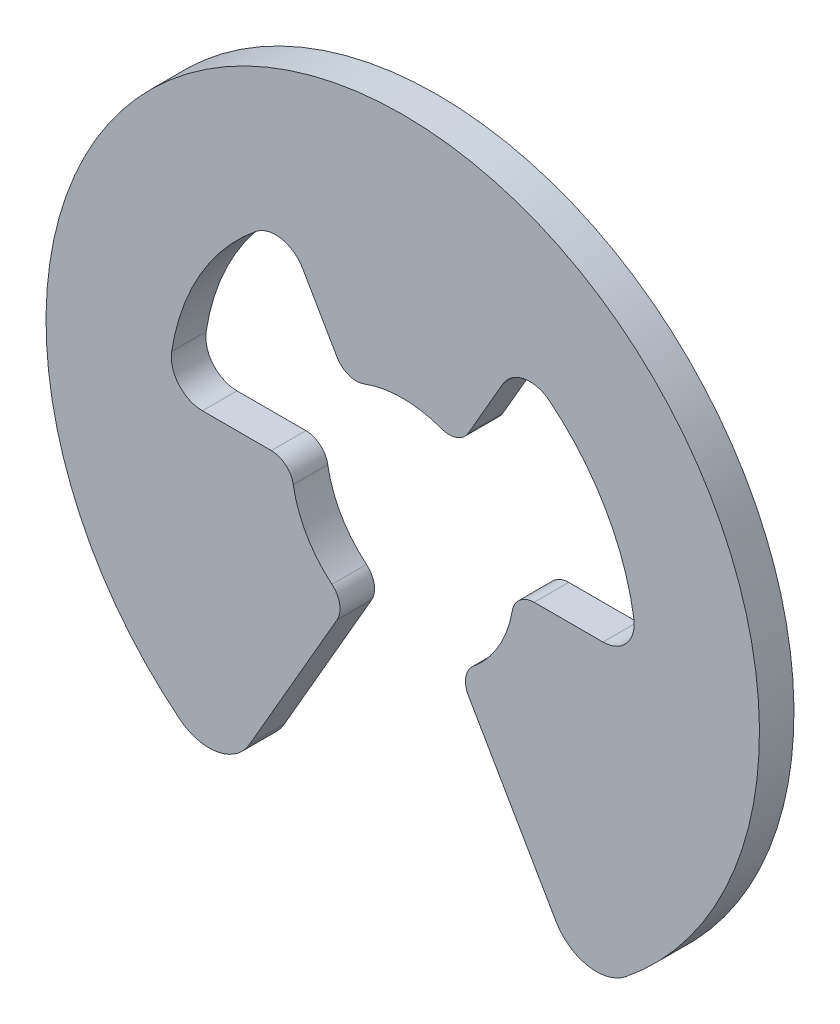
from build123d import *

# Parameters (mm, degrees)
BOSS_EXTRUDE1_DEPTH      = 0.1905
BOSS_EXTRUDE1_DEPTH_BACK = 0.1905


with BuildPart() as part:
    # Sketch1 → Boss-Extrude1 (new, two sides: drawn at the far end of the back side and taken through both)
    with BuildSketch(Plane.XY.offset(-BOSS_EXTRUDE1_DEPTH_BACK)):
        with BuildLine():
            Line((-1.690782151, -2.92852059), (-0.725045158, -1.255815051))
            ThreePointArc((-0.725045158, -1.255815051), (-0.696082706, -1.089842323), (-0.781097204, -0.944383376))
            ThreePointArc((-0.781097204, -0.944383376), (-1.061357434, -0.612775), (-1.208408596, -0.204258333))
            ThreePointArc((-1.208408596, -0.204258333), (-1.291872491, -0.057904145), (-1.450090316, 0))
            Line((-1.450090316, 0), (-2.210471848, 0))
            ThreePointArc((-2.210471848, 0), (-2.471887729, 0.120306814), (-2.55054444, 0.397119231))
            ThreePointArc((-2.55054444, 0.397119231), (-2.235449712, 1.29063752), (-1.619187526, 2.010276693))
            ThreePointArc((-1.619187526, 2.010276693), (-1.340132599, 2.080564158), (-1.105235924, 1.914324775))
            Line((-1.105235924, 1.914324775), (-0.725045158, 1.255815051))
            ThreePointArc((-0.725045158, 1.255815051), (-0.595789785, 1.147746468), (-0.427311393, 1.148641709))
            ThreePointArc((-0.427311393, 1.148641709), (0, 1.22555), (0.427311393, 1.148641709))
            ThreePointArc((0.427311393, 1.148641709), (0.595789785, 1.147746468), (0.725045158, 1.255815051))
            Line((0.725045158, 1.255815051), (1.105235924, 1.914324775))
            ThreePointArc((1.105235924, 1.914324775), (1.340132631, 2.080564164), (1.619187578, 2.010276651))
            ThreePointArc((1.619187578, 2.010276651), (2.235449717, 1.290637512), (2.550544433, 0.397119278))
            ThreePointArc((2.550544433, 0.397119278), (2.471887745, 0.120306832), (2.210471848, 0))
            Line((2.210471848, 0), (1.450090316, 0))
            ThreePointArc((1.450090316, 0), (1.291872491, -0.057904145), (1.208408596, -0.204258333))
            ThreePointArc((1.208408596, -0.204258333), (1.061357434, -0.612775), (0.781097204, -0.944383376))
            ThreePointArc((0.781097204, -0.944383376), (0.696082706, -1.089842323), (0.725045158, -1.255815051))
            Line((0.725045158, -1.255815051), (1.690782151, -2.92852059))
            ThreePointArc((1.690782151, -2.92852059), (2.042375748, -3.177738803), (2.460517356, -3.073405821))
            ThreePointArc((2.460517356, -3.073405821), (0, 3.937), (-2.460517356, -3.073405821))
            ThreePointArc((-2.460517356, -3.073405821), (-2.042375748, -3.177738803), (-1.690782151, -2.92852059))
        make_face()
    extrude(amount=BOSS_EXTRUDE1_DEPTH + BOSS_EXTRUDE1_DEPTH_BACK)


solid = part.part
